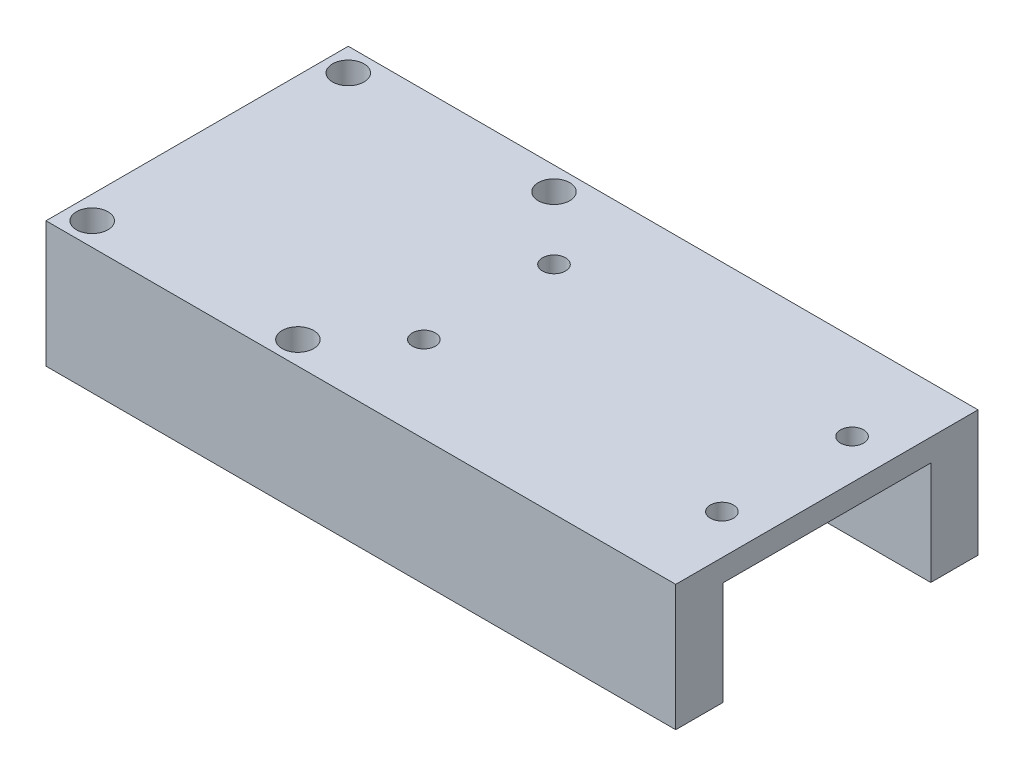
from build123d import *

# Parameters (mm, degrees)
SKETCH1_W           = 30
SKETCH1_H           = 36
BOSS_EXTRUDE1_DEPTH = 30
SKETCH3_R           = 12.375
CUT_EXTRUDE1_DEPTH  = 40
SKETCH5_R           = 1.875
CUT_EXTRUDE2_DEPTH  = 40
CUT_EXTRUDE3_START  = 15
SKETCH7_W           = 36
SKETCH7_H           = 15
CUT_EXTRUDE3_DEPTH  = 31
BOSS_EXTRUDE2_DEPTH = 45
SKETCH9_R           = 1.375
CUT_EXTRUDE4_DEPTH  = 10


with BuildPart() as part:
    # Sketch1 → Boss-Extrude1 (new body)
    with BuildSketch(Plane(origin=(0, 0, 0), x_dir=(1, 0, 0), z_dir=(0, 1, 0))):
        Rectangle(SKETCH1_W, SKETCH1_H)
    extrude(amount=BOSS_EXTRUDE1_DEPTH)

    # Sketch3 → Cut-Extrude1 (cut)
    with BuildSketch(Plane(origin=(15, 0, 0), x_dir=(0, 0, -1), z_dir=(1, 0, 0))):
        with Locations((0, 15)):
            Circle(SKETCH3_R)
    extrude(amount=-CUT_EXTRUDE1_DEPTH, mode=Mode.SUBTRACT)

    # Sketch5 → Cut-Extrude2 (cut)
    with BuildSketch(Plane(origin=(0, 30, 0), x_dir=(1, 0, 0), z_dir=(0, 1, 0))):
        with Locations((-12.25, 15.25)):
            Circle(SKETCH5_R)
        with Locations((-12.25, -15.25)):
            Circle(SKETCH5_R)
        with Locations((12.25, -15.25)):
            Circle(SKETCH5_R)
        with Locations((12.25, 15.25)):
            Circle(SKETCH5_R)
    extrude(amount=-CUT_EXTRUDE2_DEPTH, mode=Mode.SUBTRACT)

    # Sketch7 → Cut-Extrude3 (cut, through all)
    with BuildSketch(Plane(origin=(0, 0, 0), x_dir=(0, 0, -1), z_dir=(1, 0, 0)).offset(CUT_EXTRUDE3_START)):
        with Locations((0, 7.5)):
            Rectangle(SKETCH7_W, SKETCH7_H)
    extrude(amount=-CUT_EXTRUDE3_DEPTH, mode=Mode.SUBTRACT)

    # Sketch8 → Boss-Extrude2 (add)
    with BuildSketch(Plane(origin=(15, 0, 0), x_dir=(0, 0, -1), z_dir=(1, 0, 0))):
        Polygon((-18, 30), (18, 30), (18, 27.331397605), (18, 15), (12.375, 15), (12.375, 27.331397605), (-12.375, 27.331397605), (-12.375, 15), (-18, 15), (-18, 27.331397605), align=None)
    extrude(amount=BOSS_EXTRUDE2_DEPTH)

    # Sketch9 → Cut-Extrude4 (cut)
    with BuildSketch(Plane(origin=(0, 30, 0), x_dir=(1, 0, 0), z_dir=(0, 1, 0))):
        with Locations((19.75, 7.75)):
            Circle(SKETCH9_R)
        with Locations((19.75, -7.75)):
            Circle(SKETCH9_R)
        with Locations((55.25, -7.75)):
            Circle(SKETCH9_R)
        with Locations((55.25, 7.75)):
            Circle(SKETCH9_R)
    extrude(amount=-CUT_EXTRUDE4_DEPTH, mode=Mode.SUBTRACT)


solid = part.part
